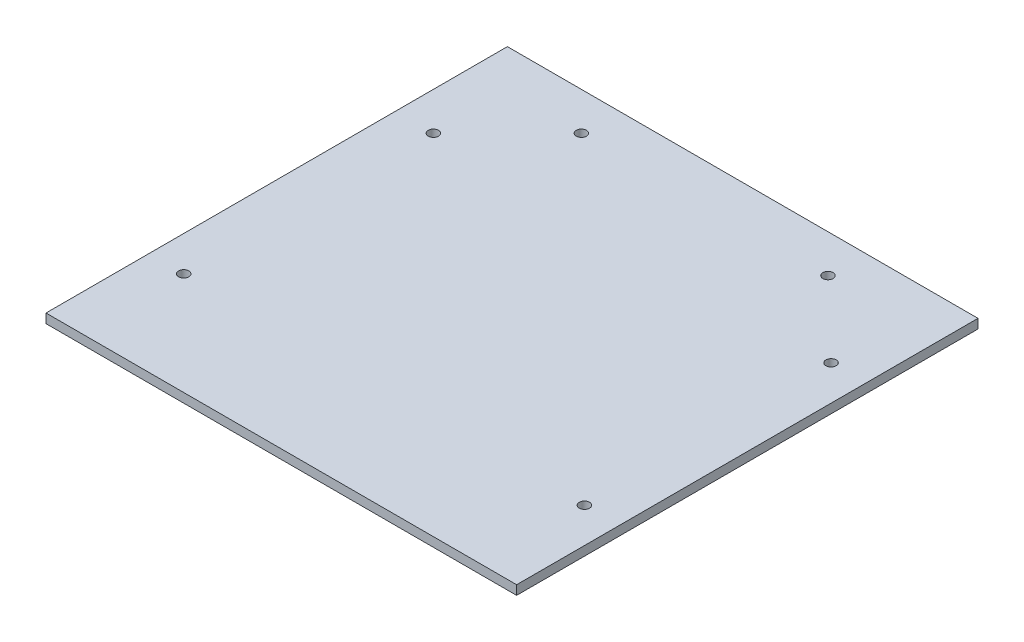
from build123d import *

# Parameters (mm, degrees)
SKETCH1_W           = 229
SKETCH1_H           = 224.5
BOSS_EXTRUDE1_DEPTH = 4.5
CUT_EXTRUDE1_REACH  = 6.5
SKETCH2_R           = 2.5


with BuildPart() as part:
    # Sketch1 → Boss-Extrude1 (new body)
    with BuildSketch(Plane(origin=(0, 0, 0), x_dir=(1, 0, 0), z_dir=(0, 1, 0))):
        Rectangle(SKETCH1_W, SKETCH1_H)
    extrude(amount=BOSS_EXTRUDE1_DEPTH)

    # Sketch2 → Cut-Extrude1 (cut, up to next)
    with BuildSketch(Plane(origin=(0, 0, 0), x_dir=(-1, 0, 0), z_dir=(0, -1, 0)), mode=Mode.PRIVATE) as cut_extrude1_sk1:
        with Locations((97.5, -62.25)):
            Circle(SKETCH2_R)
    cut_extrude1_tool1 = extrude(cut_extrude1_sk1.sketch, amount=-CUT_EXTRUDE1_REACH, mode=Mode.PRIVATE) & part.part
    add(cut_extrude1_tool1.solids().sort_by_distance((-97.5, 0, 62.25))[0], mode=Mode.SUBTRACT)
    # Sketch2 → Cut-Extrude1 (cut, up to next)
    with BuildSketch(Plane(origin=(0, 0, 0), x_dir=(-1, 0, 0), z_dir=(0, -1, 0)), mode=Mode.PRIVATE) as cut_extrude1_sk2:
        with Locations((96, 57.75)):
            Circle(SKETCH2_R)
    cut_extrude1_tool2 = extrude(cut_extrude1_sk2.sketch, amount=-CUT_EXTRUDE1_REACH, mode=Mode.PRIVATE) & part.part
    add(cut_extrude1_tool2.solids().sort_by_distance((-96, 0, -57.75))[0], mode=Mode.SUBTRACT)
    # Sketch2 → Cut-Extrude1 (cut, up to next)
    with BuildSketch(Plane(origin=(0, 0, 0), x_dir=(-1, 0, 0), z_dir=(0, -1, 0)), mode=Mode.PRIVATE) as cut_extrude1_sk3:
        with Locations((60, 93.75)):
            Circle(SKETCH2_R)
    cut_extrude1_tool3 = extrude(cut_extrude1_sk3.sketch, amount=-CUT_EXTRUDE1_REACH, mode=Mode.PRIVATE) & part.part
    add(cut_extrude1_tool3.solids().sort_by_distance((-60, 0, -93.75))[0], mode=Mode.SUBTRACT)
    # Sketch2 → Cut-Extrude1 (cut, up to next)
    with BuildSketch(Plane(origin=(0, 0, 0), x_dir=(-1, 0, 0), z_dir=(0, -1, 0)), mode=Mode.PRIVATE) as cut_extrude1_sk4:
        with Locations((-60, 93.75)):
            Circle(SKETCH2_R)
    cut_extrude1_tool4 = extrude(cut_extrude1_sk4.sketch, amount=-CUT_EXTRUDE1_REACH, mode=Mode.PRIVATE) & part.part
    add(cut_extrude1_tool4.solids().sort_by_distance((60, 0, -93.75))[0], mode=Mode.SUBTRACT)
    # Sketch2 → Cut-Extrude1 (cut, up to next)
    with BuildSketch(Plane(origin=(0, 0, 0), x_dir=(-1, 0, 0), z_dir=(0, -1, 0)), mode=Mode.PRIVATE) as cut_extrude1_sk5:
        with Locations((-97.5, -62.25)):
            Circle(SKETCH2_R)
    cut_extrude1_tool5 = extrude(cut_extrude1_sk5.sketch, amount=-CUT_EXTRUDE1_REACH, mode=Mode.PRIVATE) & part.part
    add(cut_extrude1_tool5.solids().sort_by_distance((97.5, 0, 62.25))[0], mode=Mode.SUBTRACT)
    # Sketch2 → Cut-Extrude1 (cut, up to next)
    with BuildSketch(Plane(origin=(0, 0, 0), x_dir=(-1, 0, 0), z_dir=(0, -1, 0)), mode=Mode.PRIVATE) as cut_extrude1_sk6:
        with Locations((-97.5, 57.75)):
            Circle(SKETCH2_R)
    cut_extrude1_tool6 = extrude(cut_extrude1_sk6.sketch, amount=-CUT_EXTRUDE1_REACH, mode=Mode.PRIVATE) & part.part
    add(cut_extrude1_tool6.solids().sort_by_distance((97.5, 0, -57.75))[0], mode=Mode.SUBTRACT)


solid = part.part
